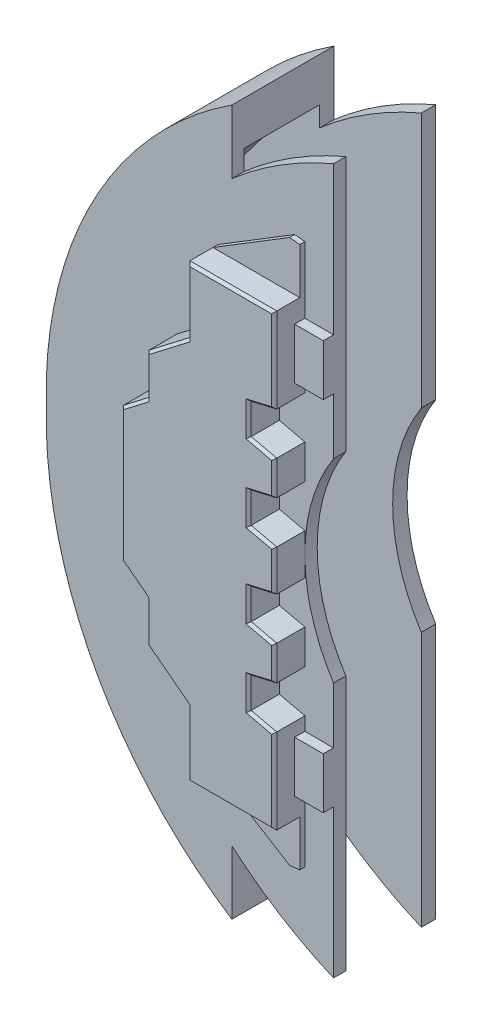
from build123d import *

# Parameters (mm, degrees)
BOSS_EXTRUDE1_DEPTH = 5
BOSS_EXTRUDE2_DEPTH = 3
SKETCH3_W           = 2.803061543
SKETCH3_H           = 5
BOSS_EXTRUDE3_DEPTH = 1
BOSS_EXTRUDE4_DEPTH = 0.5
SKETCH5_W           = 7.386047788
SKETCH5_H           = 39
CHAMFER2_SIZE       = 0.25


with BuildPart() as part:
    # Sketch1 → Boss-Extrude1 (new body, symmetric)
    with BuildSketch(Plane.XY):
        with BuildLine():
            Line((-14.696938457, 34.5), (-14.696938457, 9.5))
            ThreePointArc((-14.696938457, 9.5), (-16.784612343, 4.952452777), (-17.5, 0))
            Line((-17.5, 0), (-42.802853896, 0))
            ThreePointArc((-42.802853896, 0), (-38.211284713, 19.612097715), (-24.644146108, 34.5))
            Line((-24.644146108, 34.5), (-24.644146108, 28.265103266))
            ThreePointArc((-24.644146108, 28.265103266), (-19.916041725, 31.774223547), (-14.696938457, 34.5))
        make_face()
    boss_extrude1 = extrude(amount=BOSS_EXTRUDE1_DEPTH, both=True)

    # Sketch2 → Boss-Extrude2 (add)
    with BuildSketch(Plane.XY.offset(5)):
        Polygon((-26, 0), (-17.5, 0), (-17.5, 2), (-20, 2.577874668), (-20, 5.577874668), (-17.5, 6.155749336), (-17.5, 9.524542718), (-20, 10.102417386), (-20, 13.102417386), (-17.5, 13.680292054), (-17.5, 15), (-17.5, 22), (-26, 22), (-26, 15.5), (-30.001513248, 12.421912886), (-30.001513248, 8.421912886), (-32.5, 6.5), (-32.5, 0), align=None)
    boss_extrude2 = extrude(amount=BOSS_EXTRUDE2_DEPTH)

    # Sketch3 → Boss-Extrude3 (add)
    with BuildSketch(Plane.XY.offset(5)):
        with Locations((-16.098469229, 17.5)):
            Rectangle(SKETCH3_W, SKETCH3_H)
    boss_extrude3 = extrude(amount=BOSS_EXTRUDE3_DEPTH)

    # Sketch4 → Boss-Extrude4 (add)
    with BuildSketch(Plane.XY.offset(5)):
        Polygon((-26, 22), (-18.495062021, 26.599255094), (-17.5, 26.5), (-17.5, 22), align=None)
    boss_extrude4 = extrude(amount=BOSS_EXTRUDE4_DEPTH)

    # Sketch5 → Cut-Revolve1 (revolve, cut)
    with BuildSketch(Plane(origin=(0, 0, 0), x_dir=(0, 0, -1), z_dir=(1, 0, 0))):
        with Locations((-0.102834864, 19.5)):
            Rectangle(SKETCH5_W, SKETCH5_H)
    cut_revolve1 = revolve(axis=Axis((0, 0, 3.795858758), (0, 0, -1)), mode=Mode.SUBTRACT)

    # Mirror1: Boss-Extrude1, Boss-Extrude2, Boss-Extrude3, Boss-Extrude4, Cut-Revolve1 across plane
    add(boss_extrude1.mirror(Plane.ZX))
    add(boss_extrude2.mirror(Plane.ZX))
    add(boss_extrude3.mirror(Plane.ZX))
    add(boss_extrude4.mirror(Plane.ZX))
    add(cut_revolve1.mirror(Plane.ZX), mode=Mode.SUBTRACT)

    # Chamfer2
    chamfer2_edges = [part.edges().sort_by_distance(p)[0] for p in [
        (-20, -11.602417386, 8),
        (-18.75, -9.813480052, 8),
        (-17.5, -7.840146027, 8),
        (-18.75, -5.866812002, 8),
        (-31.250756624, -7.460956443, 8),
        (-30.001513248, -10.421912886, 8),
        (-28.000756624, -13.960956443, 8),
        (-21.75, -22, 8),
        (-18.75, -13.39135472, 8),
        (-20, -4.077874668, 8),
        (-18.75, -2.288937334, 8),
        (-26, -18.75, 8),
        (-17.5, -17.840146027, 8),
        (-17.5, 17.840146027, 8),
        (-26, 18.75, 8),
        (-18.75, 2.288937334, 8),
        (-20, 4.077874668, 8),
        (-20, 11.602417386, 8),
        (-18.75, 13.39135472, 8),
        (-21.75, 22, 8),
        (-28.000756624, 13.960956443, 8),
        (-30.001513248, 10.421912886, 8),
        (-31.250756624, 7.460956443, 8),
        (-32.5, 0, 8),
        (-17.5, 0, 8),
        (-18.75, 5.866812002, 8),
        (-17.5, 7.840146027, 8),
        (-18.75, 9.813480052, 8),
    ]]
    chamfer(chamfer2_edges, length=CHAMFER2_SIZE)


solid = part.part
